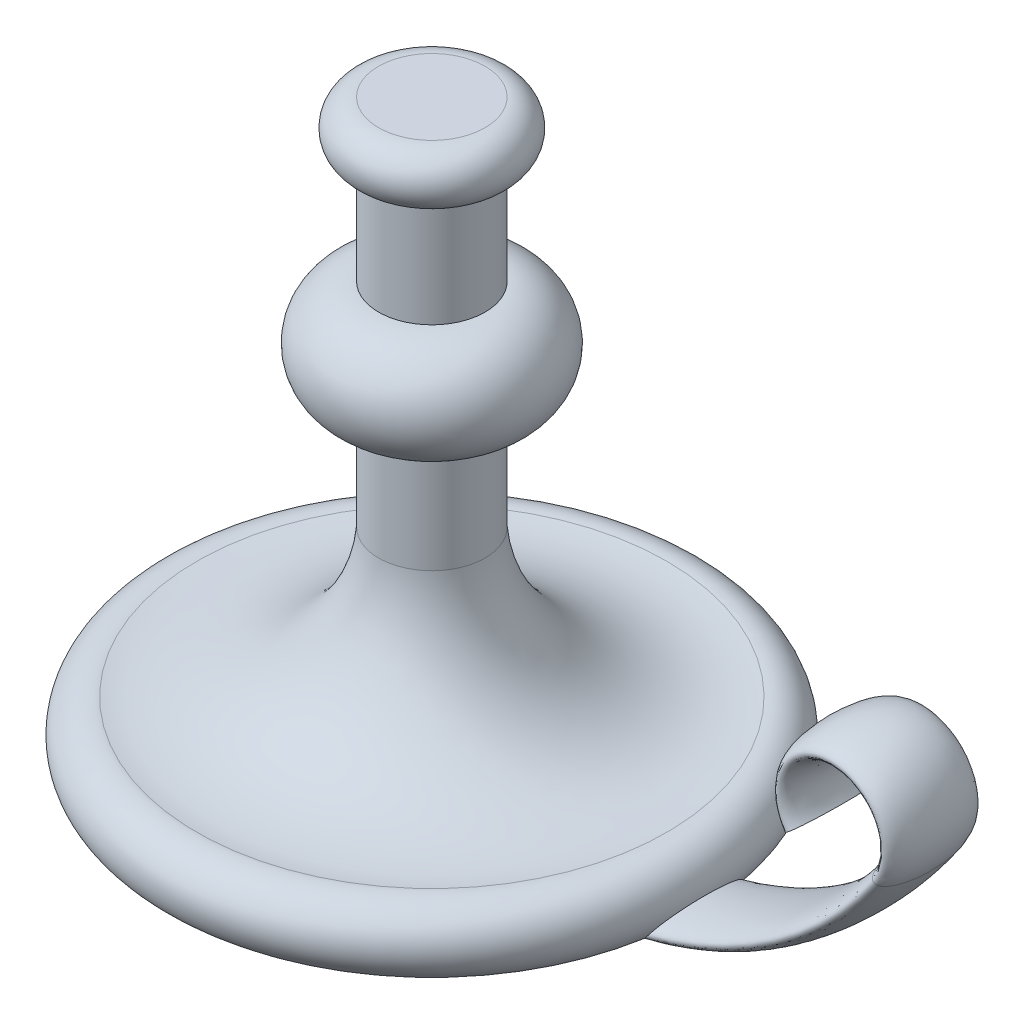
from build123d import *

# Parameters (mm, degrees)
SKETCH9_RX = 444.5
SKETCH9_RY = 127


with BuildPart() as part:
    # Sketch1 → Revolve1 (revolve)
    with BuildSketch(Plane.XY):
        with BuildLine():
            Line((0, 0), (0, 5588))
            Line((0, 5588), (508, 5588))
            ThreePointArc((508, 5588), (762, 5334), (508, 5080))
            Line((508, 5080), (508, 4064))
            ThreePointArc((508, 4064), (1016, 3556), (508, 3048))
            Line((508, 3048), (508, 2032))
            ThreePointArc((508, 2032), (1070.536195673, 955.258410962), (2241.535796037, 631.871093719))
            ThreePointArc((2241.535796037, 631.871093719), (2602.71680746, 339.787078592), (2286, 0))
            Line((2286, 0), (0, 0))
        make_face()
    revolve(axis=Axis((0, 0, 0), (0, 1, 0)))

    # Sweep1: sweep along a path in Sketch4
    with BuildLine(Plane.XY) as sweep1_path:
        Line((0, -3.476560285), (1524, -3.476560285))
        ThreePointArc((1524, -3.476560285), (3297.458485559, 434.440255688), (4663.238601954, 1647.523439715))
        ThreePointArc((4663.238601954, 1647.523439715), (4244.673455027, 2443.390106382), (3826.1083081, 1647.523439715))
    # Sketch9 → Sweep1 (sweep)
    with BuildSketch(Plane(origin=(0, 0, 0), x_dir=(0, 0, -1), z_dir=(1, 0, 0))):
        with Locations(Location((0, 0), (0, 0, 180))):
            Ellipse(SKETCH9_RX, SKETCH9_RY)
    sweep(path=sweep1_path.line)


solid = part.part
